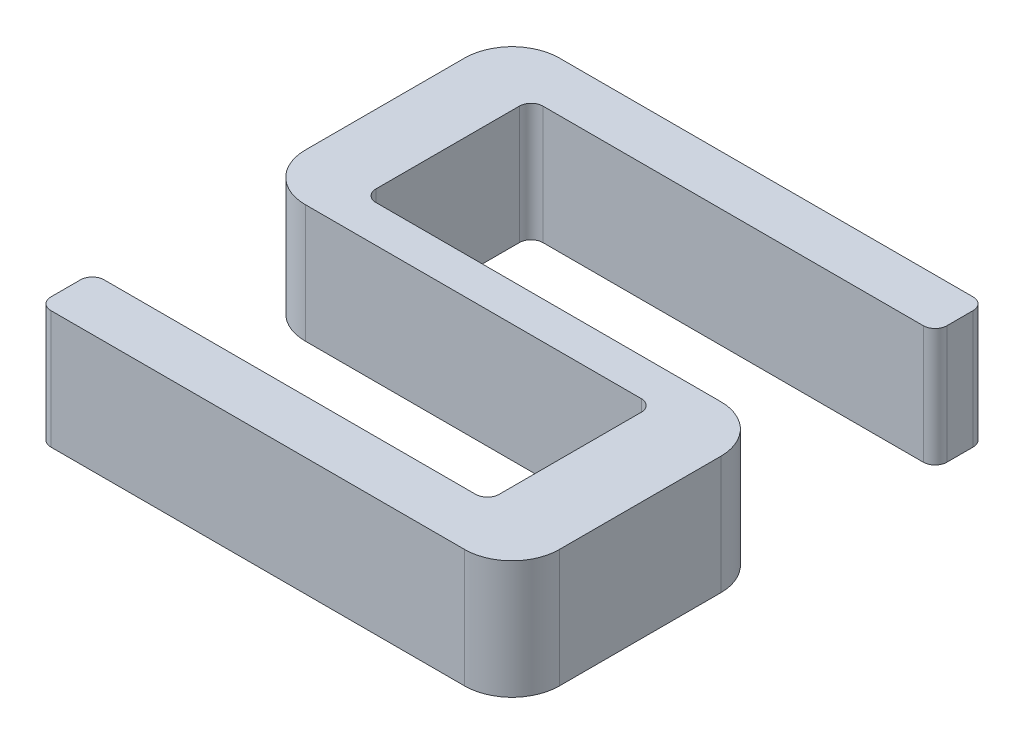
from build123d import *

# Parameters (mm, degrees)
BOSS_EXTRUDE1_DEPTH = 10
FILLET1_R           = 4
FILLET2_R           = 1


with BuildPart() as part:
    # Sketch1 → Boss-Extrude1 (new body)
    with BuildSketch(Plane(origin=(0, 0, 0), x_dir=(1, 0, 0), z_dir=(0, 1, 0))):
        Polygon((0, 4.504109696), (0, 0), (33.415268294, 0), (40, 0), (40, 4.504109696), (40, 18.518496951), (40, 21.657719696), (33.415268294, 21.657719696), (5.834954176, 21.657719696), (5.834954176, 35.784222049), (40, 35.784222049), (40, 40), (5.834954176, 40), (0, 40), (0, 35.784222049), (0, 21.657719696), (0, 18.518496951), (33.415268294, 18.518496951), (33.415268294, 4.504109696), align=None)
    extrude(amount=BOSS_EXTRUDE1_DEPTH)

    # Fillet1
    fillet1_edges = [part.edges().sort_by_distance(p)[0] for p in [
        (0, 5, -18.518496951),
        (0, 5, -40),
        (40, 5, -21.657719696),
        (40, 5, 0),
    ]]
    fillet(fillet1_edges, radius=FILLET1_R)

    # Fillet2
    fillet2_edges = [part.edges().sort_by_distance(p)[0] for p in [
        (33.415268294, 5, -18.518496951),
        (40, 5, -40),
        (40, 5, -35.784222049),
        (5.834954176, 5, -35.784222049),
        (5.834954176, 5, -21.657719696),
        (0, 5, 0),
        (0, 5, -4.504109696),
        (33.415268294, 5, -4.504109696),
    ]]
    fillet(fillet2_edges, radius=FILLET2_R)


solid = part.part
